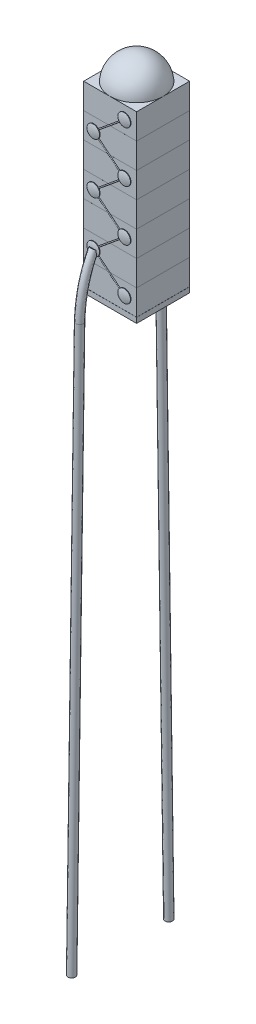
from build123d import *

# Parameters (mm, degrees)
SKETCH1_W                = 5
SKETCH1_H                = 5
BOSS_EXTRUDE1_DEPTH      = 2.4
LPATTERN3_COUNT          = 7
LPATTERN3_PITCH          = 2.4001
SKETCH2_W                = 5
SKETCH2_H                = 5
BOSS_EXTRUDE2_DEPTH      = 0.5
SKETCH7_R                = 0.6
BOSS_EXTRUDE6_DEPTH      = 0.05
DOME1_FACE_RADIUS        = 0.6
DOME1_HEIGHT             = 0.1
DOME5_FACE_RADIUS        = 0.6
DOME5_HEIGHT             = 0.1
DOME6_FACE_RADIUS        = 0.6
DOME6_HEIGHT             = 0.1
DOME7_FACE_RADIUS        = 0.6
DOME7_HEIGHT             = 0.1
SKETCH9_R                = 0.05
SKETCH18_R               = 0.35
DOME10_FACE_RADIUS       = 0.6
DOME10_HEIGHT            = 0.1
DOME11_FACE_RADIUS       = 0.6
DOME11_HEIGHT            = 0.1
DOME12_FACE_RADIUS       = 0.6
DOME12_HEIGHT            = 0.1
MIRROR20_COPY_1_SKETCH_R = 0.05


with BuildPart() as part:
    # Sketch1 → Boss-Extrude1 (new body)
    with BuildSketch(Plane(origin=(0, 0, 0), x_dir=(1, 0, 0), z_dir=(0, 1, 0))):
        Rectangle(SKETCH1_W, SKETCH1_H)
    extrude(amount=BOSS_EXTRUDE1_DEPTH)


with BuildPart() as lpattern3_1:
    # LPattern3: pattern copy
    add(part.part.moved(Location(Vector(0, 1, 0) * (1 * LPATTERN3_PITCH))))


with BuildPart() as lpattern3_2:
    # LPattern3: pattern copy
    add(part.part.moved(Location(Vector(0, 1, 0) * (2 * LPATTERN3_PITCH))))


with BuildPart() as lpattern3_3:
    # LPattern3: pattern copy
    add(part.part.moved(Location(Vector(0, 1, 0) * (3 * LPATTERN3_PITCH))))

    # Sketch7 → Boss-Extrude6 (add)
    with BuildSketch(Plane.XY.offset(2.5)):
        with Locations((1.368076751, 10.8004)):
            Circle(SKETCH7_R)
        with Locations(Location((-1.547788486, 8.4, 0), (0, 0, 180))):
            Circle(SKETCH7_R)
        with Locations((1.368076751, 6.0002)):
            Circle(SKETCH7_R)
        with Locations((-1.547788486, 3.6001)):
            Circle(SKETCH7_R)
        with Locations((1.368076751, 1.2)):
            Circle(SKETCH7_R)
        with Locations((-1.547788486, 13.2005)):
            Circle(SKETCH7_R)
        with Locations((1.368076751, 15.6006)):
            Circle(SKETCH7_R)
    boss_extrude6 = extrude(amount=BOSS_EXTRUDE6_DEPTH)


with BuildPart() as lpattern3_4:
    # LPattern3: pattern copy
    add(part.part.moved(Location(Vector(0, 1, 0) * (4 * LPATTERN3_PITCH))))


with BuildPart() as lpattern3_5:
    # LPattern3: pattern copy
    add(part.part.moved(Location(Vector(0, 1, 0) * (5 * LPATTERN3_PITCH))))


with BuildPart() as lpattern3_6:
    # LPattern3: pattern copy
    add(part.part.moved(Location(Vector(0, 1, 0) * (6 * LPATTERN3_PITCH))))


with BuildPart() as body_8:
    # Sketch2 → Boss-Extrude2 (new body)
    with BuildSketch(Plane(origin=(0, -0.01, 0), x_dir=(-1, 0, 0), z_dir=(0, -1, 0))):
        Rectangle(SKETCH2_W, SKETCH2_H)
    extrude(amount=BOSS_EXTRUDE2_DEPTH)


with BuildPart() as boss_extrude6_piece_1:
    # of the separate pieces the step leaves, piece 1, a body of its own (boss_extrude6_pieces)
    add(lpattern3_3.part.solids().sort_by_distance((-2.5, 7.2003, -2.5))[0])


with BuildPart() as boss_extrude6_piece_2:
    # of the separate pieces the step leaves, piece 2, a body of its own (boss_extrude6_pieces)
    add(lpattern3_3.part.solids().sort_by_distance((-0.947788486, 3.6001, 2.5))[0])

    # Dome6: a dome of height H over a round flat face of radius A is a cap of a sphere of radius (A * A + H * H) / (2 * H)
    dome6_r = (DOME6_FACE_RADIUS * DOME6_FACE_RADIUS + DOME6_HEIGHT * DOME6_HEIGHT) / (2 * DOME6_HEIGHT)
    dome6_base = Plane((-1.547788486, 3.6001, 2.55), z_dir=(0, 0, 1))
    with Locations(dome6_base.offset(DOME6_HEIGHT - dome6_r)):
        dome6_ball = Sphere(dome6_r, mode=Mode.PRIVATE)
    add(split(dome6_ball, bisect_by=dome6_base, keep=Keep.TOP, mode=Mode.PRIVATE))


with BuildPart() as boss_extrude6_piece_3:
    # of the separate pieces the step leaves, piece 3, a body of its own (boss_extrude6_pieces)
    add(lpattern3_3.part.solids().sort_by_distance((-0.947788486, 13.2005, 2.5))[0])

    # Dome11: a dome of height H over a round flat face of radius A is a cap of a sphere of radius (A * A + H * H) / (2 * H)
    dome11_r = (DOME11_FACE_RADIUS * DOME11_FACE_RADIUS + DOME11_HEIGHT * DOME11_HEIGHT) / (2 * DOME11_HEIGHT)
    dome11_base = Plane((-1.547788486, 13.2005, 2.55), z_dir=(0, 0, 1))
    with Locations(dome11_base.offset(DOME11_HEIGHT - dome11_r)):
        dome11_ball = Sphere(dome11_r, mode=Mode.PRIVATE)
    add(split(dome11_ball, bisect_by=dome11_base, keep=Keep.TOP, mode=Mode.PRIVATE))


with BuildPart() as boss_extrude6_piece_4:
    # of the separate pieces the step leaves, piece 4, a body of its own (boss_extrude6_pieces)
    add(lpattern3_3.part.solids().sort_by_distance((1.968076751, 1.2, 2.5))[0])

    # Dome7: a dome of height H over a round flat face of radius A is a cap of a sphere of radius (A * A + H * H) / (2 * H)
    dome7_r = (DOME7_FACE_RADIUS * DOME7_FACE_RADIUS + DOME7_HEIGHT * DOME7_HEIGHT) / (2 * DOME7_HEIGHT)
    dome7_base = Plane((1.368076751, 1.2, 2.55), z_dir=(0, 0, 1))
    with Locations(dome7_base.offset(DOME7_HEIGHT - dome7_r)):
        dome7_ball = Sphere(dome7_r, mode=Mode.PRIVATE)
    add(split(dome7_ball, bisect_by=dome7_base, keep=Keep.TOP, mode=Mode.PRIVATE))


with BuildPart() as boss_extrude6_piece_5:
    # of the separate pieces the step leaves, piece 5, a body of its own (boss_extrude6_pieces)
    add(lpattern3_3.part.solids().sort_by_distance((1.968076751, 6.0002, 2.5))[0])

    # Dome5: a dome of height H over a round flat face of radius A is a cap of a sphere of radius (A * A + H * H) / (2 * H)
    dome5_r = (DOME5_FACE_RADIUS * DOME5_FACE_RADIUS + DOME5_HEIGHT * DOME5_HEIGHT) / (2 * DOME5_HEIGHT)
    dome5_base = Plane((1.368076751, 6.0002, 2.55), z_dir=(0, 0, 1))
    with Locations(dome5_base.offset(DOME5_HEIGHT - dome5_r)):
        dome5_ball = Sphere(dome5_r, mode=Mode.PRIVATE)
    add(split(dome5_ball, bisect_by=dome5_base, keep=Keep.TOP, mode=Mode.PRIVATE))


with BuildPart() as boss_extrude6_piece_6:
    # of the separate pieces the step leaves, piece 6, a body of its own (boss_extrude6_pieces)
    add(lpattern3_3.part.solids().sort_by_distance((1.968076751, 10.8004, 2.5))[0])

    # Dome12: a dome of height H over a round flat face of radius A is a cap of a sphere of radius (A * A + H * H) / (2 * H)
    dome12_r = (DOME12_FACE_RADIUS * DOME12_FACE_RADIUS + DOME12_HEIGHT * DOME12_HEIGHT) / (2 * DOME12_HEIGHT)
    dome12_base = Plane((1.368076751, 10.8004, 2.55), z_dir=(0, 0, 1))
    with Locations(dome12_base.offset(DOME12_HEIGHT - dome12_r)):
        dome12_ball = Sphere(dome12_r, mode=Mode.PRIVATE)
    add(split(dome12_ball, bisect_by=dome12_base, keep=Keep.TOP, mode=Mode.PRIVATE))


with BuildPart() as boss_extrude6_piece_7:
    # of the separate pieces the step leaves, piece 7, a body of its own (boss_extrude6_pieces)
    add(lpattern3_3.part.solids().sort_by_distance((1.968076751, 15.6006, 2.5))[0])

    # Dome10: a dome of height H over a round flat face of radius A is a cap of a sphere of radius (A * A + H * H) / (2 * H)
    dome10_r = (DOME10_FACE_RADIUS * DOME10_FACE_RADIUS + DOME10_HEIGHT * DOME10_HEIGHT) / (2 * DOME10_HEIGHT)
    dome10_base = Plane((1.368076751, 15.6006, 2.55), z_dir=(0, 0, 1))
    with Locations(dome10_base.offset(DOME10_HEIGHT - dome10_r)):
        dome10_ball = Sphere(dome10_r, mode=Mode.PRIVATE)
    add(split(dome10_ball, bisect_by=dome10_base, keep=Keep.TOP, mode=Mode.PRIVATE))


with BuildPart() as mirror34_copies:
    # Mirror34: Boss-Extrude6 across plane
    add(boss_extrude6.mirror(Plane.XY))


with BuildPart() as lpattern3_4_1:
    add(lpattern3_4.part)

    # the copy of mirror34_joined that lands on this body joins it
    add(mirror34_copies.part.solids().sort_by_distance((1.968076751, 10.8004, -2.5))[0])


with BuildPart() as boss_extrude6_piece_1_1:
    add(boss_extrude6_piece_1.part)

    # the copy of mirror34_joined that lands on this body joins it
    add(mirror34_copies.part.solids().sort_by_distance((-2.147788486, 8.4, -2.5))[0])

    # Dome1: a dome of height H over a round flat face of radius A is a cap of a sphere of radius (A * A + H * H) / (2 * H)
    dome1_r = (DOME1_FACE_RADIUS * DOME1_FACE_RADIUS + DOME1_HEIGHT * DOME1_HEIGHT) / (2 * DOME1_HEIGHT)
    dome1_base = Plane((-1.547788486, 8.4, 2.55), z_dir=(0, 0, 1))
    with Locations(dome1_base.offset(DOME1_HEIGHT - dome1_r)):
        dome1_ball = Sphere(dome1_r, mode=Mode.PRIVATE)
    add(split(dome1_ball, bisect_by=dome1_base, keep=Keep.TOP, mode=Mode.PRIVATE))


with BuildPart() as lpattern3_2_1:
    add(lpattern3_2.part)

    # the copy of mirror34_joined that lands on this body joins it
    add(mirror34_copies.part.solids().sort_by_distance((1.968076751, 6.0002, -2.5))[0])


with BuildPart() as lpattern3_1_1:
    add(lpattern3_1.part)

    # the copy of mirror34_joined that lands on this body joins it
    add(mirror34_copies.part.solids().sort_by_distance((-0.947788486, 3.6001, -2.5))[0])


with BuildPart() as part_1:
    add(part.part)

    # the copy of mirror34_joined that lands on this body joins it
    add(mirror34_copies.part.solids().sort_by_distance((1.968076751, 1.2, -2.5))[0])


    add(lpattern3_1_1.part)  # Sweep1 merges LPattern3_1

    add(lpattern3_2_1.part)  # Sweep1 merges LPattern3_2

    add(boss_extrude6_piece_1_1.part)  # Sweep1 merges Boss-Extrude6 piece 1

    add(boss_extrude6_piece_2.part)  # Sweep1 merges Boss-Extrude6 piece 2

    add(boss_extrude6_piece_4.part)  # Sweep1 merges Boss-Extrude6 piece 4

    add(boss_extrude6_piece_5.part)  # Sweep1 merges Boss-Extrude6 piece 5
    # Sweep1: sweep along a path in Sketch8
    with BuildLine(Plane.XY.offset(2.5)) as sweep1_path:
        Line((-1.547788486, 8.4), (1.368027635, 5.999940428))
        Line((1.368027635, 5.999940428), (-1.547788486, 3.6001))
        Line((-1.547788486, 3.6001), (1.368076751, 1.2))
    # Sketch9 → Sweep1 (sweep)
    with BuildSketch(Plane(origin=(-1.547788486, 8.4, 2.5), x_dir=(0, 0, -1), z_dir=(0.7720862388953024, -0.6355177729288978, 0))):
        Circle(SKETCH9_R)
    sweep1 = sweep(path=sweep1_path.line, transition=Transition.RIGHT)

    # Sweep2: sweep along a path in Sketch17
    with BuildLine() as sweep2_path:  # in the path sketch's own coordinates; laid on its plane below (add() does not lay a ready-made edge on the line's plane)
        Line((4.58491824, -54.772897522), (3.836541994, -1.715359601))
        add(Edge.make_bspline(
            [(3.836541994, -1.715359601), (3.75813778, 0.222344556), (3.367938728, 1.999301306), (2.494410501, 3.611060957)],
            knots=[0, 0, 0, 0, 1, 1, 1, 1], degree=3))
    # Sketch18 → Sweep2 (sweep)
    with BuildSketch(Plane(origin=(-1.55, -54.772897522, 4.58491824), x_dir=(-1, 0, 0), z_dir=(0, -0.9999005394148865, 0.014103590954746347))):
        Circle(SKETCH18_R)
    sweep2 = sweep(path=Plane.ZY.offset(1.55) * sweep2_path.line, transition=Transition.RIGHT)

    # Mirror2: Sweep2 across plane
    add(sweep2.mirror(Plane.XY))

    # Mirror12: Sweep1 across plane
    add(sweep1.mirror(Plane.ZX.offset(8.4)))

    # Mirror20: Sweep1 across plane
    add(sweep1.mirror(Plane.XY))

    # Mirror20 copy 1: sweep along a path in Mirror20 copy 1 path
    with BuildLine(Plane(origin=(0, 16.8, -2.5), x_dir=(1, 0, 0), z_dir=(0, 0, -1))) as mirror20_copy_1_path:
        Line((-1.547788486, 8.4), (1.368027635, 5.999940428))
        Line((1.368027635, 5.999940428), (-1.547788486, 3.6001))
        Line((-1.547788486, 3.6001), (1.368076751, 1.2))
    # Mirror20 copy 1 sketch → Mirror20 copy 1 (sweep)
    with BuildSketch(Plane(origin=(-1.547788486, 8.4, -2.5), x_dir=(0, 0, 1), z_dir=(0.7720862388953024, 0.6355177729288978, 0))):
        Circle(MIRROR20_COPY_1_SKETCH_R)
    sweep(path=mirror20_copy_1_path.line, transition=Transition.RIGHT)


with BuildPart() as lpattern3_5_1:
    add(lpattern3_5.part)

    # the copy of mirror34_joined that lands on this body joins it
    add(mirror34_copies.part.solids().sort_by_distance((-0.947788486, 13.2005, -2.5))[0])


with BuildPart() as lpattern3_6_1:
    add(lpattern3_6.part)

    # the copy of mirror34_joined that lands on this body joins it
    add(mirror34_copies.part.solids().sort_by_distance((1.968076751, 15.6006, -2.5))[0])

    # Sketch19 → Revolve-Thin1 (revolve)
    with BuildSketch(Plane(origin=(0, 0, 0), x_dir=(0, 0, -1), z_dir=(1, 0, 0)), mode=Mode.PRIVATE) as revolve_thin1_sk:
        with BuildLine():
            ThreePointArc((0, 19.119751686), (-1.767766953, 18.387518639), (-2.5, 16.619751686))
            Line((-2.5, 16.619751686), (-2.4999, 16.619751686))
            ThreePointArc((-2.4999, 16.619751686), (-1.767696242, 18.387447928), (0, 19.119651686))
            Line((0, 19.119651686), (0, 19.119751686))
        make_face()
    revolve(revolve_thin1_sk.sketch.rotate(Axis((0, 19.119751686, 0), (0, -1, 0)), 180), axis=Axis((0, 19.119751686, 0), (0, -1, 0)))


solid = Compound([body_8.part, boss_extrude6_piece_3.part, boss_extrude6_piece_6.part, boss_extrude6_piece_7.part, lpattern3_4_1.part, part_1.part, lpattern3_5_1.part, lpattern3_6_1.part])
